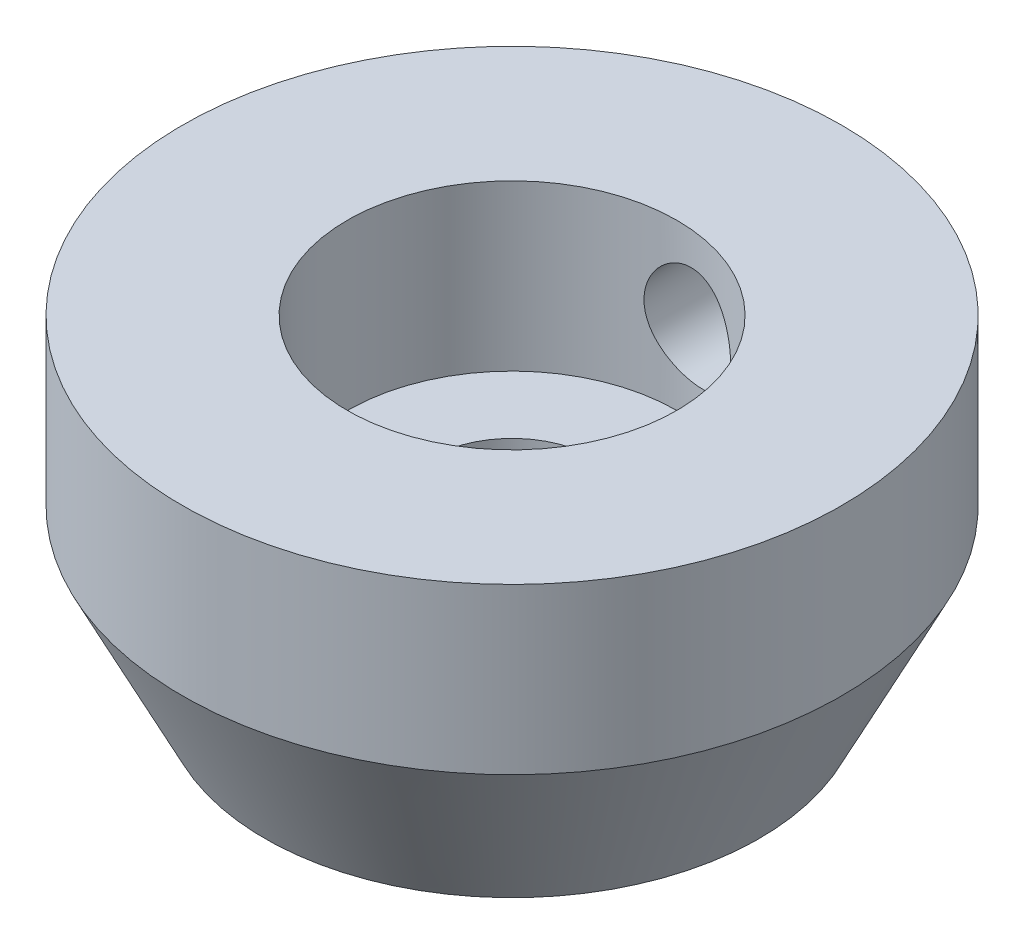
from build123d import *

# Parameters (mm, degrees)
SKETCH2_R          = 3
CUT_EXTRUDE1_DEPTH = 23


with BuildPart() as part:
    # Sketch1 → Revolve1 (revolve)
    with BuildSketch(Plane.XY):
        Polygon((8.827160494, 15.308641975), (18.827160494, 15.308641975), (18.827160494, 5.308641975), (13.827160494, -4.691358025), (3.827160494, -4.691358025), (3.827160494, 5.308641975), (8.827160494, 5.308641975), align=None)
    revolve(axis=Axis((-1.172839506, 0, 0), (0, 1, 0)))

    # Sketch2 → Cut-Extrude1 (cut)
    with BuildSketch(Plane.XY):
        with Locations((0, 10.308641975)):
            Circle(SKETCH2_R)
    extrude(amount=-CUT_EXTRUDE1_DEPTH, mode=Mode.SUBTRACT)


solid = part.part
